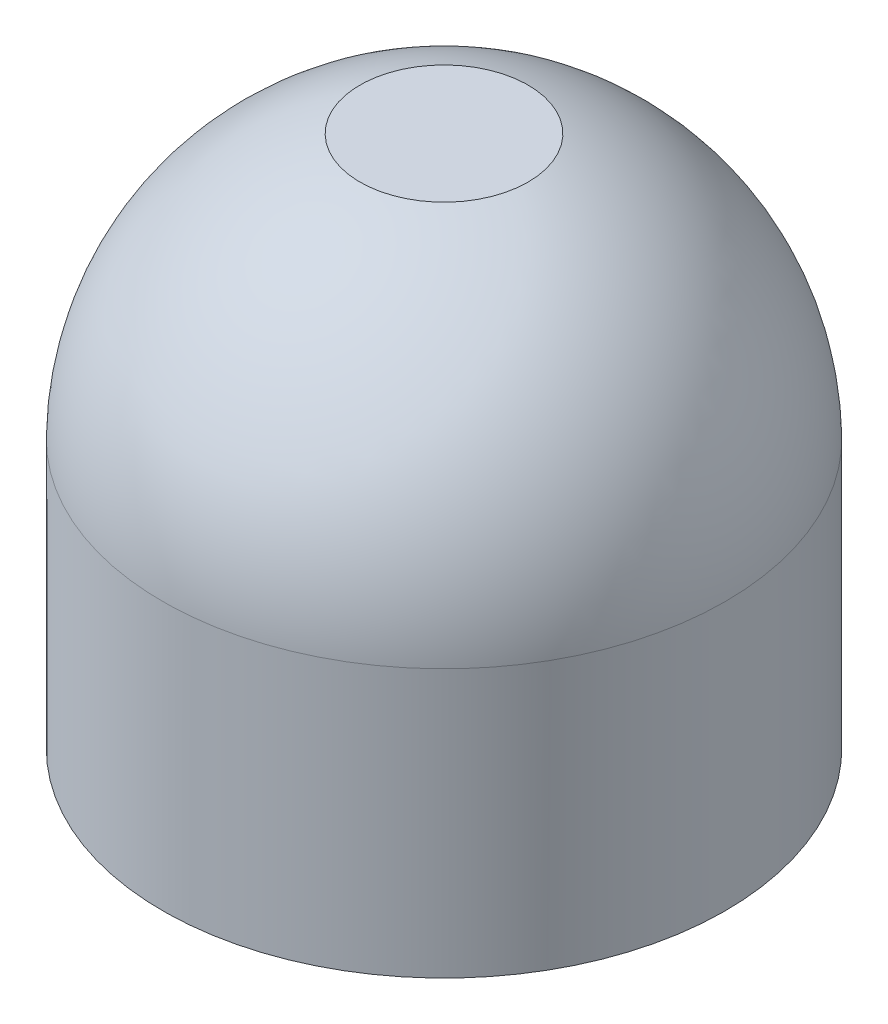
from build123d import *

# Parameters (mm, degrees)
SKETCH1_R           = 5.25
SKETCH1_R_2         = 4.5
BOSS_EXTRUDE1_DEPTH = 5
CUT_EXTRUDE1_DEPTH  = 5
CUT_EXTRUDE2_DEPTH  = 2
SKETCH6_R           = 2
CUT_EXTRUDE4_DEPTH  = 0.35


with BuildPart() as part:
    # Sketch1 → Boss-Extrude1 (new body)
    with BuildSketch(Plane(origin=(0, 0, 0), x_dir=(1, 0, 0), z_dir=(0, 1, 0))):
        Circle(SKETCH1_R)
        Circle(SKETCH1_R_2, mode=Mode.SUBTRACT)
    extrude(amount=BOSS_EXTRUDE1_DEPTH)

    # Sketch2 → Cut-Extrude1 (cut)
    with BuildSketch(Plane(origin=(0, 0, 0), x_dir=(1, 0, 0), z_dir=(0, 1, 0))):
        Polygon((1.327689147, 3.795637322), (1.327689147, 5.701107087), (-1.5, 5.701107087), (-1.5, 3.701107087), align=None)
    extrude(amount=CUT_EXTRUDE1_DEPTH, mode=Mode.SUBTRACT)

    # Sketch4 → Revolve1 (revolve)
    with BuildSketch(Plane.XY):
        with BuildLine():
            Line((5.25, 5), (0, 5))
            Line((0, 5), (0, 10.18))
            ThreePointArc((0, 10.18), (3.687644912, 8.667004979), (5.25, 5))
        make_face()
    revolve(axis=Axis((0, 5, 0), (0, 1, 0)))

    # Sketch5 → Cut-Extrude2 (cut)
    with BuildSketch(Plane(origin=(0, 5, 0), x_dir=(-1, 0, 0), z_dir=(0, -1, 0))):
        with BuildLine():
            Line((1.5, 3.436931771), (1.5, 6))
            Line((1.5, 6), (-1.327689147, 6))
            Line((-1.327689147, 6), (-1.327689147, 3.507098734))
            ThreePointArc((-1.327689147, 3.507098734), (-0.093024772, -3.748846008), (1.5, 3.436931771))
        make_face()
    extrude(amount=-CUT_EXTRUDE2_DEPTH, mode=Mode.SUBTRACT)

    # Sketch6 → Cut-Extrude4 (cut)
    with BuildSketch(Plane(origin=(0, 10.29, 0), x_dir=(-1, 0, 0), z_dir=(0, -1, 0))):
        Circle(SKETCH6_R)
    extrude(amount=CUT_EXTRUDE4_DEPTH, mode=Mode.SUBTRACT)


solid = part.part
